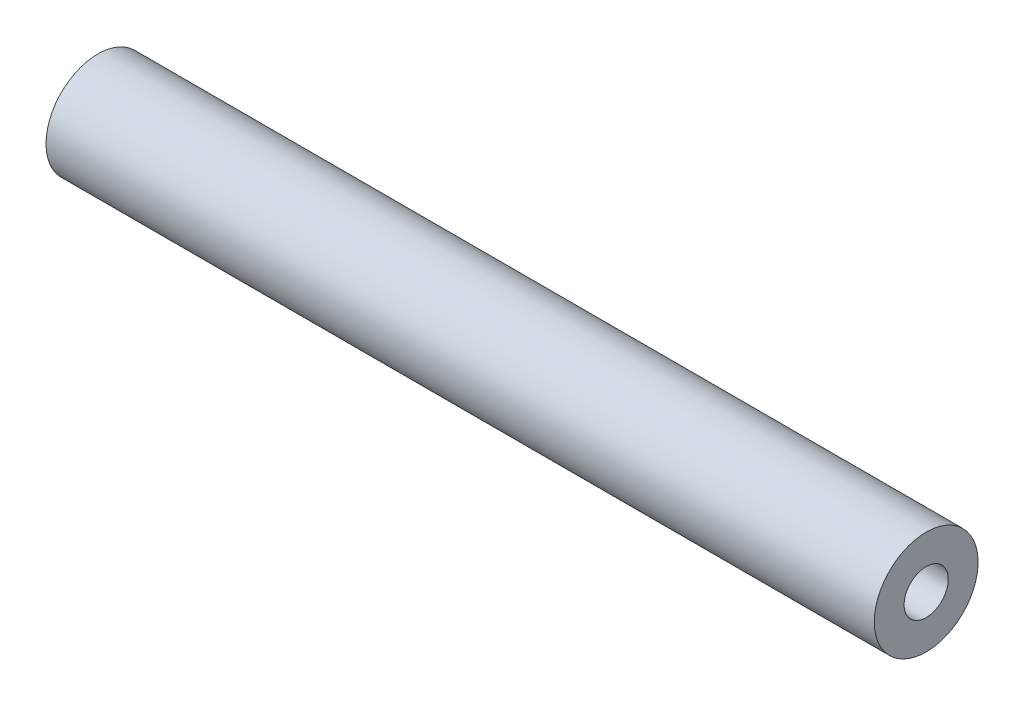
from build123d import *

# Parameters (mm, degrees)
SKETCH1_W = 19.05
SKETCH1_H = 0.6858


with BuildPart() as part:
    # Sketch1 → Revolve1 (revolve)
    with BuildSketch(Plane(origin=(0, 0, 0), x_dir=(1, 0, 0), z_dir=(0, 1, 0))):
        with Locations((9.525, 0.8509)):
            Rectangle(SKETCH1_W, SKETCH1_H)
    revolve(axis=Axis((0, 0, 0), (1, 0, 0)))


solid = part.part
